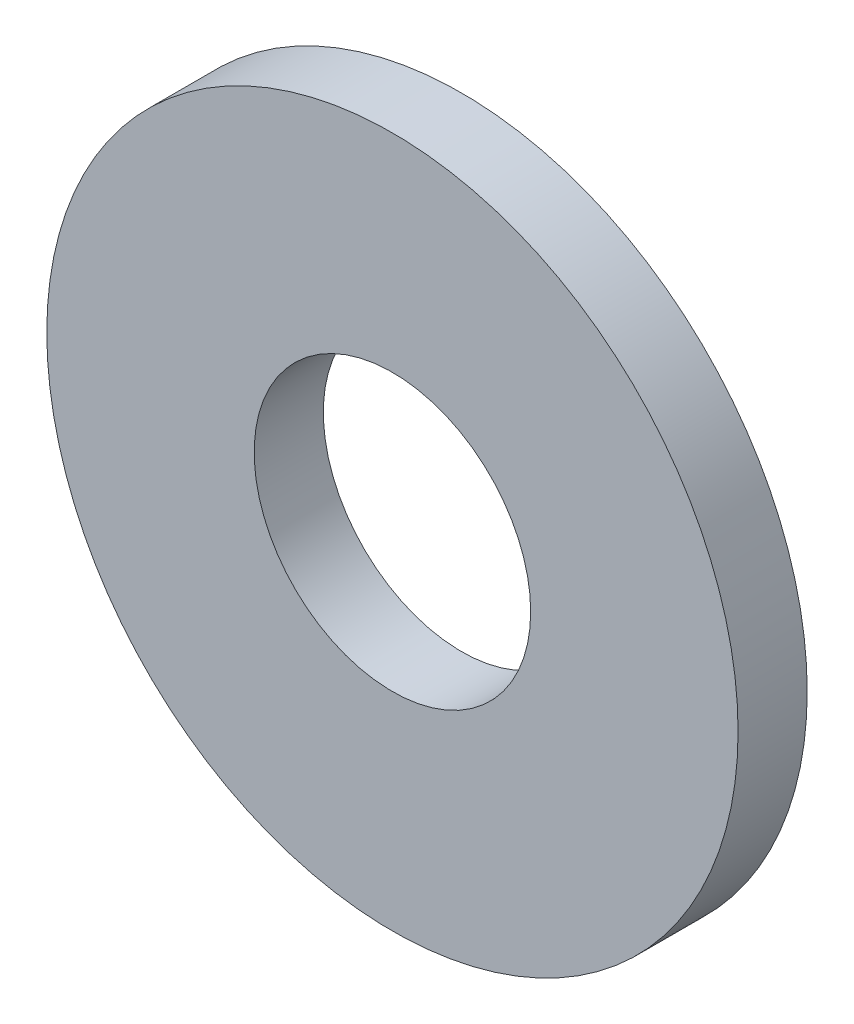
from build123d import *

# Parameters (mm, degrees)
SKETCH_1_R      = 2.5
SKETCH_1_R_2    = 1
EXTRUDE_1_DEPTH = 0.25


with BuildPart() as part:
    # 草图1 → 凸台-拉伸1 (new body, symmetric)
    with BuildSketch(Plane.XY):
        Circle(SKETCH_1_R)
        Circle(SKETCH_1_R_2, mode=Mode.SUBTRACT)
    extrude(amount=EXTRUDE_1_DEPTH, both=True)


solid = part.part
